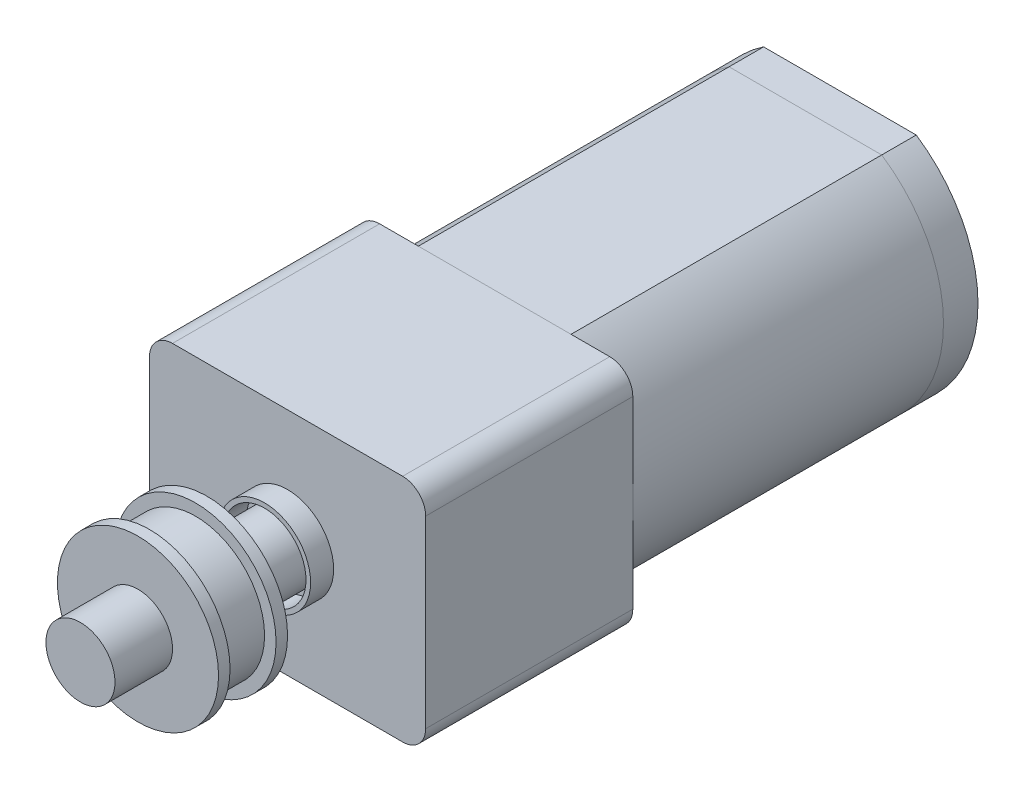
from build123d import *

# Parameters (mm, degrees)
SKETCH1_W           = 6.63324958
SKETCH1_H           = 10
BOSS_EXTRUDE1_DEPTH = 13.5
SKETCH2_W           = 12
SKETCH2_H           = 10
BOSS_EXTRUDE3_DEPTH = 9
SKETCH4_R           = 2
SKETCH4_R_2         = 1.8
BOSS_EXTRUDE4_DEPTH = 1
SKETCH5_R           = 1.5
BOSS_EXTRUDE5_DEPTH = 9
BOSS_EXTRUDE6_DEPTH = 1.5
SKETCH7_R           = 2.5
SKETCH7_R_2         = 1.5
BOSS_EXTRUDE7_DEPTH = 1.5
FILLET1_R           = 1


with BuildPart() as part:
    # Sketch1 → Boss-Extrude1 (new body)
    with BuildSketch(Plane.XY):
        with BuildLine():
            Line((-3.31662479, -5), (-3.31662479, 5))
            ThreePointArc((-3.31662479, 5), (-6, 0), (-3.31662479, -5))
        make_face()
        with BuildLine():
            Line((3.31662479, -5), (3.31662479, 5))
            ThreePointArc((3.31662479, 5), (6, 0), (3.31662479, -5))
        make_face()
        Rectangle(SKETCH1_W, SKETCH1_H)
    extrude(amount=BOSS_EXTRUDE1_DEPTH)


with BuildPart() as body_2:
    # Sketch2 → Boss-Extrude3 (new body)
    with BuildSketch(Plane.XY.offset(13.5)):
        Rectangle(SKETCH2_W, SKETCH2_H)
    extrude(amount=BOSS_EXTRUDE3_DEPTH)

    # Sketch4 → Boss-Extrude4 (add)
    with BuildSketch(Plane.XY.offset(22.5)):
        Circle(SKETCH4_R)
        Circle(SKETCH4_R_2, mode=Mode.SUBTRACT)
    extrude(amount=BOSS_EXTRUDE4_DEPTH)

    # Fillet1
    fillet1_edges = [body_2.edges().sort_by_distance(p)[0] for p in [
        (-6, 5, 18),
        (6, 5, 18),
        (6, -5, 18),
        (-6, -5, 18),
    ]]
    fillet(fillet1_edges, radius=FILLET1_R)


with BuildPart() as body_3:
    # Sketch5 → Boss-Extrude5 (new body)
    with BuildSketch(Plane.XY.offset(22.5)):
        Circle(SKETCH5_R)
    extrude(amount=BOSS_EXTRUDE5_DEPTH)


with BuildPart() as body_4:
    # Sketch6 → Boss-Extrude6 (new body)
    with BuildSketch(Plane(origin=(0, 0, 0), x_dir=(-1, 0, 0), z_dir=(0, 0, -1))):
        with BuildLine():
            Line((3.31662479, 5), (-3.31662479, 5))
            ThreePointArc((-3.31662479, 5), (-6, 0), (-3.31662479, -5))
            Line((-3.31662479, -5), (3.31662479, -5))
            ThreePointArc((3.31662479, -5), (6, 0), (3.31662479, 5))
        make_face()
    extrude(amount=BOSS_EXTRUDE6_DEPTH)

    # Sketch7 → Boss-Extrude7 (add)
    with BuildSketch(Plane(origin=(0, 0, -1.5), x_dir=(-1, 0, 0), z_dir=(0, 0, -1))):
        Circle(SKETCH7_R)
        Circle(SKETCH7_R_2, mode=Mode.SUBTRACT)
    extrude(amount=BOSS_EXTRUDE7_DEPTH)


with BuildPart() as body_5:
    # Sketch8 → Revolve1 (revolve)
    with BuildSketch(Plane(origin=(0, 0, 0), x_dir=(1, 0, 0), z_dir=(0, 1, 0))):
        Polygon((0, -29), (3.5, -29), (3.5, -28.5), (3, -28.5), (3, -26.5), (3.5, -26.5), (3.5, -26), (0, -26), align=None)
    revolve(axis=Axis((0, 0, 31.5), (0, 0, -1)))


solid = Compound([part.part, body_2.part, body_3.part, body_4.part, body_5.part])
